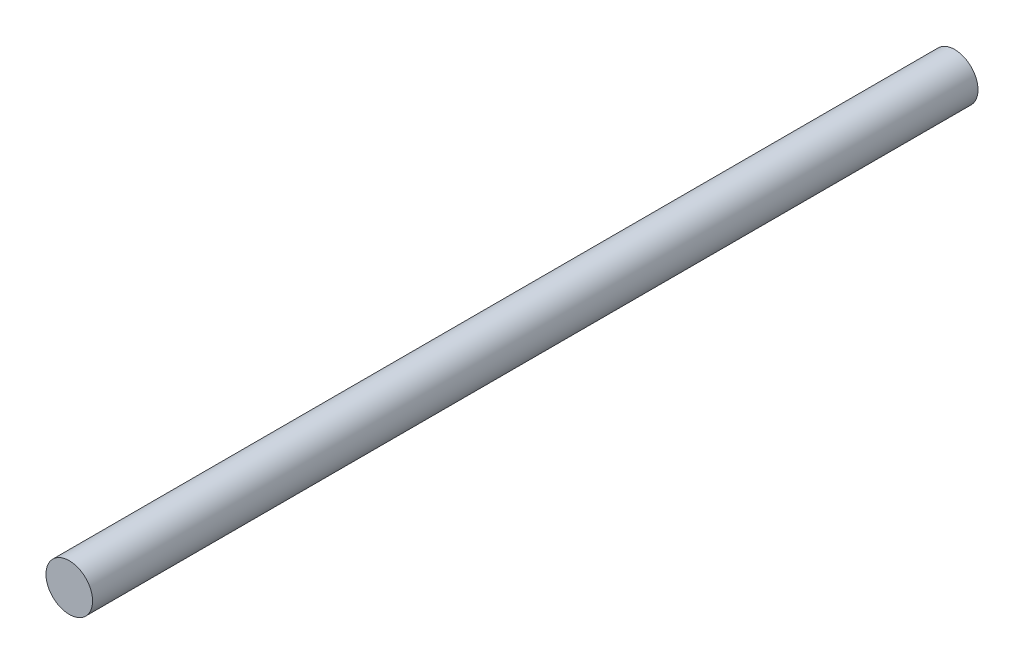
from build123d import *

# Parameters (mm, degrees)
SKETCH1_R           = 5
BOSS_EXTRUDE1_DEPTH = 190


with BuildPart() as part:
    # Sketch1 → Boss-Extrude1 (new body)
    with BuildSketch(Plane.XY):
        Circle(SKETCH1_R)
    extrude(amount=BOSS_EXTRUDE1_DEPTH)


solid = part.part
